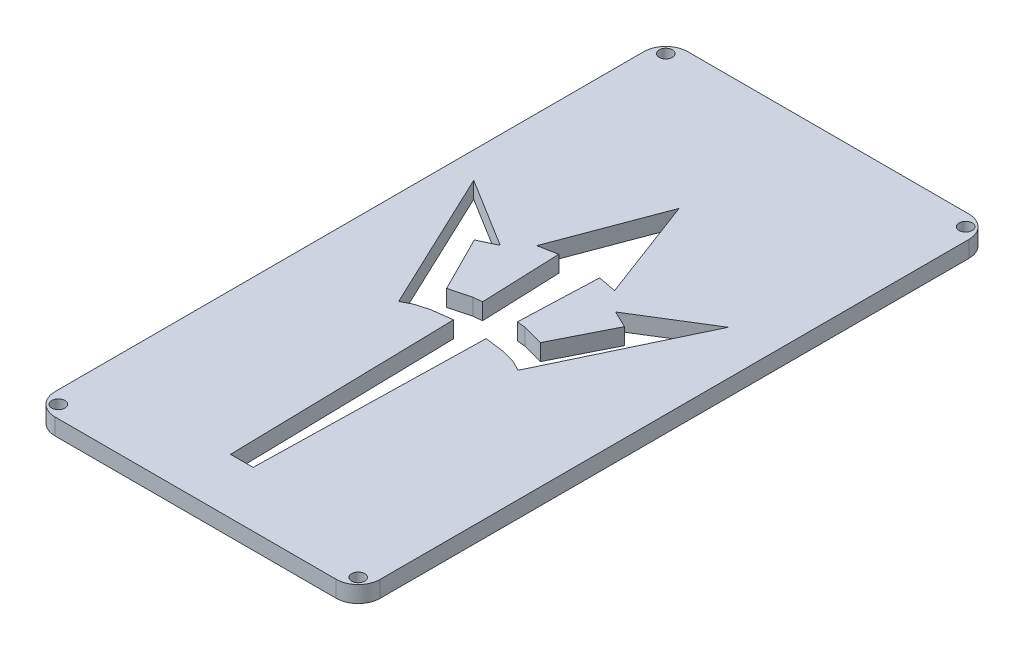
from build123d import *

# Parameters (mm, degrees)
SKETCH1_R           = 1.905
BOSS_EXTRUDE1_DEPTH = 4.7625
CUT_EXTRUDE3_DEPTH  = 5.7625


with BuildPart() as part:
    # Sketch1 → Boss-Extrude1 (new body)
    with BuildSketch(Plane(origin=(0, 0, 0), x_dir=(1, 0, 0), z_dir=(0, 1, 0))):
        with BuildLine():
            ThreePointArc((0, 176.53), (1.859871939, 181.020128061), (6.35, 182.88))
            Line((6.35, 182.88), (87.63, 182.88))
            ThreePointArc((87.63, 182.88), (92.120128061, 181.020128061), (93.98, 176.53))
            Line((93.98, 176.53), (93.98, 6.35))
            ThreePointArc((93.98, 6.35), (92.120128061, 1.859871939), (87.63, 0))
            Line((87.63, 0), (6.35, 0))
            ThreePointArc((6.35, 0), (1.859871939, 1.859871939), (0, 6.35))
            Line((0, 6.35), (0, 176.53))
        make_face()
        with Locations(Location((90.324076836, 3.655923164, 0), (0, 0, 270))):  # turned: the seam where the file's is
            Circle(SKETCH1_R, mode=Mode.SUBTRACT)
        with Locations(Location((3.655923164, 3.655923164, 0), (0, 0, 270))):  # turned: the seam where the file's is
            Circle(SKETCH1_R, mode=Mode.SUBTRACT)
        with Locations(Location((90.324076836, 179.224076836, 0), (0, 0, 270))):  # turned: the seam where the file's is
            Circle(SKETCH1_R, mode=Mode.SUBTRACT)
        with Locations(Location((3.655923164, 179.224076836, 0), (0, 0, 270))):  # turned: the seam where the file's is
            Circle(SKETCH1_R, mode=Mode.SUBTRACT)
    extrude(amount=BOSS_EXTRUDE1_DEPTH)

    # Sketch2 → Cut-Extrude3 (cut, through all)
    with BuildSketch(Plane(origin=(0, 0, 0), x_dir=(1, 0, 0), z_dir=(0, 1, 0))):
        Polygon((44.330866221, 142.412423135), (55.583348796, 112.48561291), (50.236412259, 113.523076227), (49.358559843, 90.619091365), (51.892366687, 90.359727043), (57.897684242, 88.783579573), (66.03778893, 104.904168998), (61.089973403, 107.29831442), (81.200790115, 119.747856132), (61.568701793, 78.568503007), (58.865309307, 80.004989053), (55.003504896, 81.127248207), (49.039350105, 81.92031082), (47.602864059, 16.00137357), (44.330866221, 16.001385635), (41.058234971, 16.001385635), (39.621748925, 81.920322885), (33.691252468, 81.127263288), (29.825707906, 80.005004135), (27.092397237, 78.568515072), (7.62, 119.747868197), (27.730816712, 107.298326485), (22.6233101, 104.904181063), (30.763414788, 88.783591638), (36.738802094, 90.359739108), (39.302539188, 90.61910343), (38.424686771, 113.523088292), (33.077750234, 112.485624975), align=None)
    extrude(amount=CUT_EXTRUDE3_DEPTH, mode=Mode.SUBTRACT)


solid = part.part
